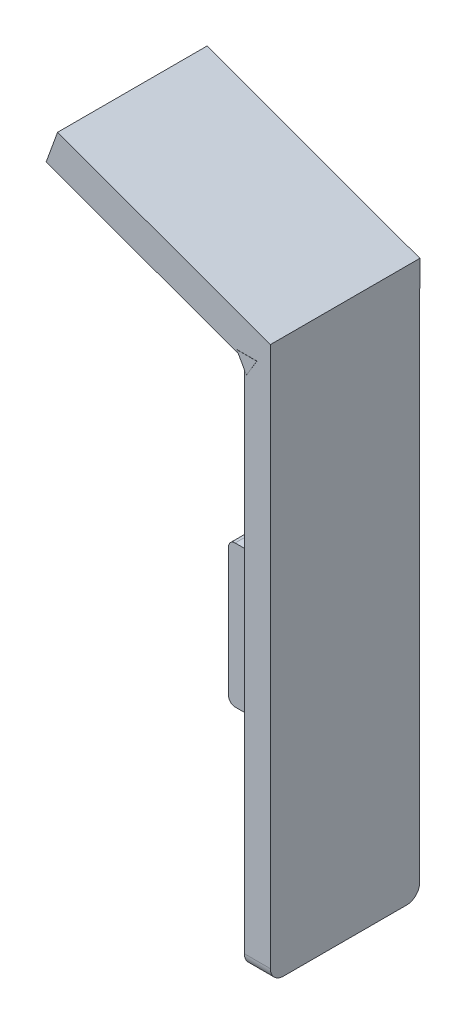
from build123d import *

# Parameters (mm, degrees)
ESQUISSE1_W         = 4
ESQUISSE1_H         = 85
BOSS_EXTRU_1_DEPTH  = 22.93
BOSS_EXTRU_5_DEPTH  = 22.95
CONG_1_R            = 2
ESQUISSE7_W         = 4
ESQUISSE7_H         = 21.820353027
BOSS_EXTRU_10_DEPTH = 25.35
CONG_14_R           = 1
CONG_15_R           = 1
BOSS_EXTRU_11_DEPTH = 1
BOSS_EXTRU_12_DEPTH = 22.95


with BuildPart() as part:
    # Esquisse1 → Boss.-Extru.1 (new body)
    with BuildSketch(Plane.XY):
        with Locations((-2, -15.95097561)):
            Rectangle(ESQUISSE1_W, ESQUISSE1_H)
    extrude(amount=BOSS_EXTRU_1_DEPTH)

    # Esquisse2 → Boss.-Extru.5 (add)
    with BuildSketch(Plane.XY.offset(22.93)):
        Polygon((-32.681935281, 38.444276031), (0, 26.54902439), (0, 22.54902439), (-4, 22.54902439), (-34.435421614, 33.626611925), align=None)
    extrude(amount=-BOSS_EXTRU_5_DEPTH)

    # Congé1
    cong_1_edges = [part.edges().sort_by_distance(p)[0] for p in [
        (-2, -58.45097561, 22.93),
        (-2, -58.45097561, 0),
    ]]
    fillet(cong_1_edges, radius=CONG_1_R)

    # Esquisse7 → Boss.-Extru.10 (add)
    with BuildSketch(Plane(origin=(0, 0, 0), x_dir=(0, 0, -1), z_dir=(1, 0, 0))):
        with Locations((-2, -32.381152124)):
            Rectangle(ESQUISSE7_W, ESQUISSE7_H)
    extrude(amount=-BOSS_EXTRU_10_DEPTH)

    # Congé14
    cong_14_edges = [part.edges().sort_by_distance(p)[0] for p in [
        (-25.35, -43.291328637, 2),
        (-25.35, -21.47097561, 2),
    ]]
    fillet(cong_14_edges, radius=CONG_14_R)

    # Congé15
    cong_15_edges = [part.edges().sort_by_distance(p)[0] for p in [
        (-14.175, -43.291328637, 0),
        (-25.35, -32.381152123, 0),
        (-14.175, -21.47097561, 0),
        (-25.057106781, -21.763868829, 0),
        (-25.057106781, -42.998435418, 0),
    ]]
    fillet(cong_15_edges, radius=CONG_15_R)

    # Esquisse10 → Boss.-Extru.11 (add)
    with BuildSketch(Plane.ZY.offset(4)):
        Polygon((7.751431337, 10.464501792), (12.751431337, 10.464501792), (12.751431337, 15.464501792), (10.751431337, 15.464501792), (10.751431337, 12.464501792), (7.751431337, 12.464501792), align=None)
    extrude(amount=BOSS_EXTRU_11_DEPTH)

    # Esquisse13 → Boss.-Extru.12 (add)
    with BuildSketch(Plane.XY):
        Polygon((-5.151966744, 23.320636857), (-3.656231692, 20.681104413), (-2.075100003, 23.320636857), align=None)
    extrude(amount=BOSS_EXTRU_12_DEPTH)


solid = part.part
